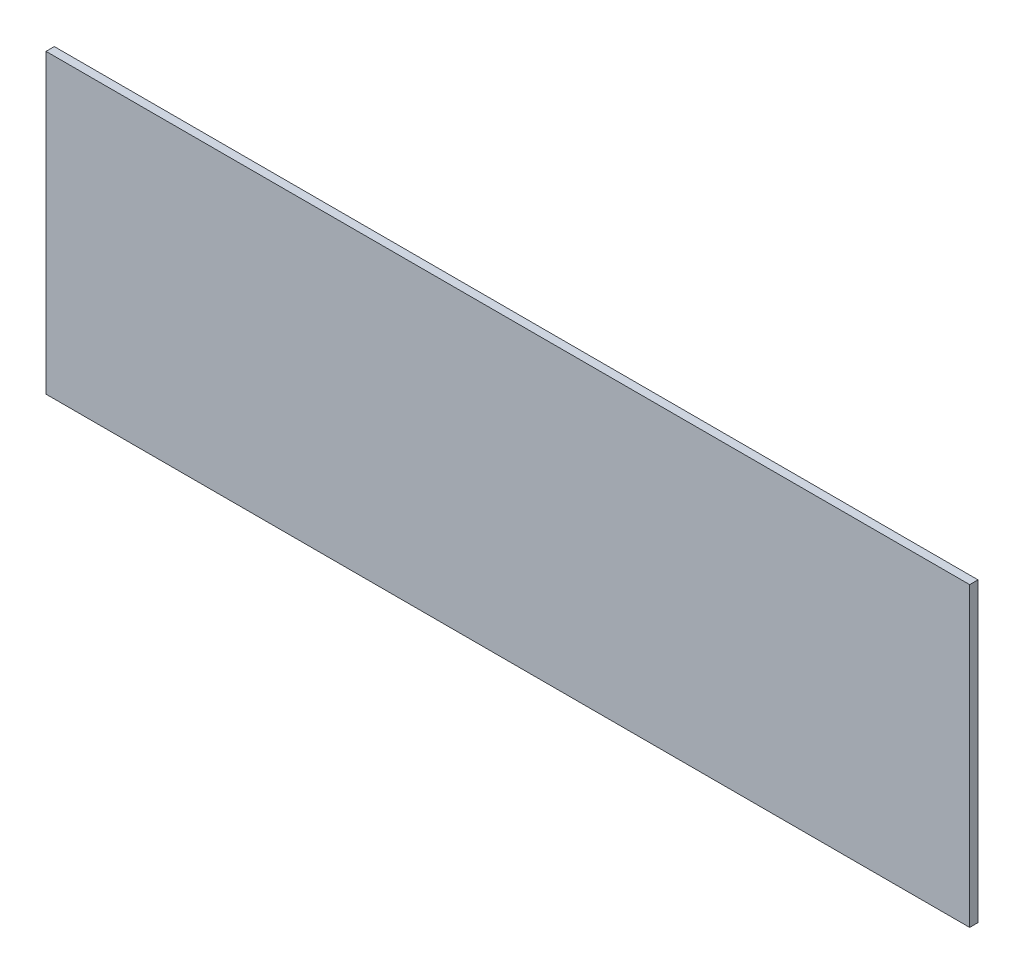
from build123d import *

# Parameters (mm, degrees)
SKETCH2_W           = 177.8
SKETCH2_H           = 57.15
BOSS_EXTRUDE1_DEPTH = 1.6


with BuildPart() as part:
    # Sketch2 → Boss-Extrude1 (new body)
    with BuildSketch(Plane.XY):
        with Locations((88.9, -28.575)):
            Rectangle(SKETCH2_W, SKETCH2_H)
    extrude(amount=BOSS_EXTRUDE1_DEPTH)


solid = part.part
